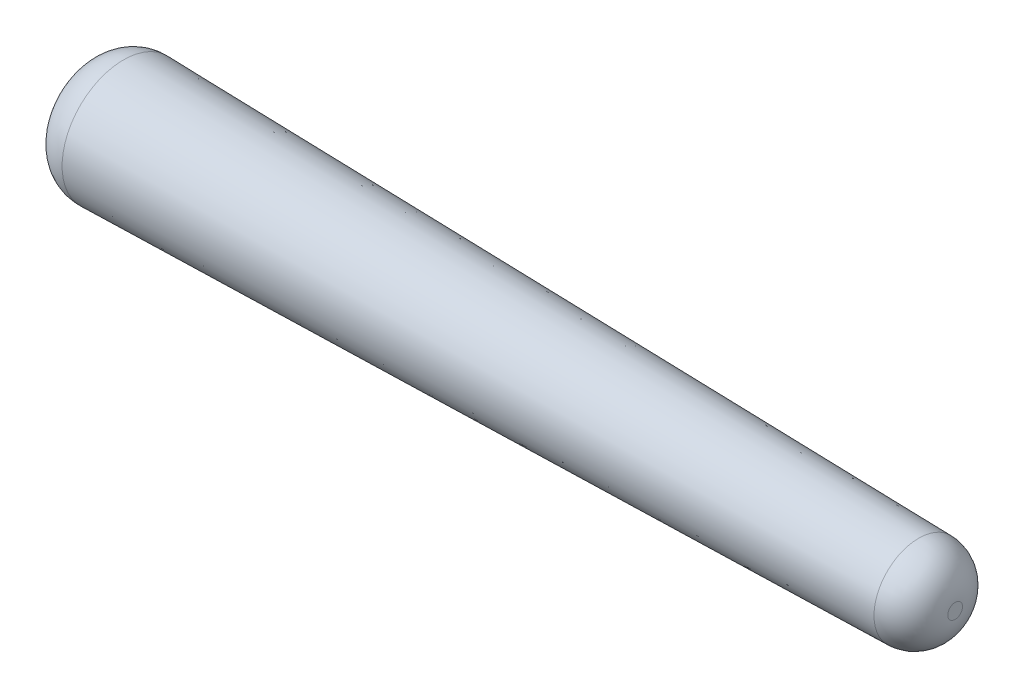
from build123d import *

# Parameters (mm, degrees)
SKETCH2_R           = 0.5
BOSS_EXTRUDE1_DEPTH = 7
BOSS_EXTRUDE1_TAPER = 1.2
FILLET1_R           = 0.3


with BuildPart() as part:
    # Sketch2 → Boss-Extrude1 (new body)
    with BuildSketch(Plane(origin=(-3.5, 0, 0), x_dir=(0, 0, -1), z_dir=(1, 0, 0))):
        Circle(SKETCH2_R)
    extrude(amount=BOSS_EXTRUDE1_DEPTH, taper=BOSS_EXTRUDE1_TAPER)

    # Fillet1
    fillet1_edges = [part.edges().sort_by_distance(p)[0] for p in [
        (-3.5, 0, 0.5),
        (3.5, 0, 0.353370903),
    ]]
    fillet(fillet1_edges, radius=FILLET1_R)


solid = part.part
